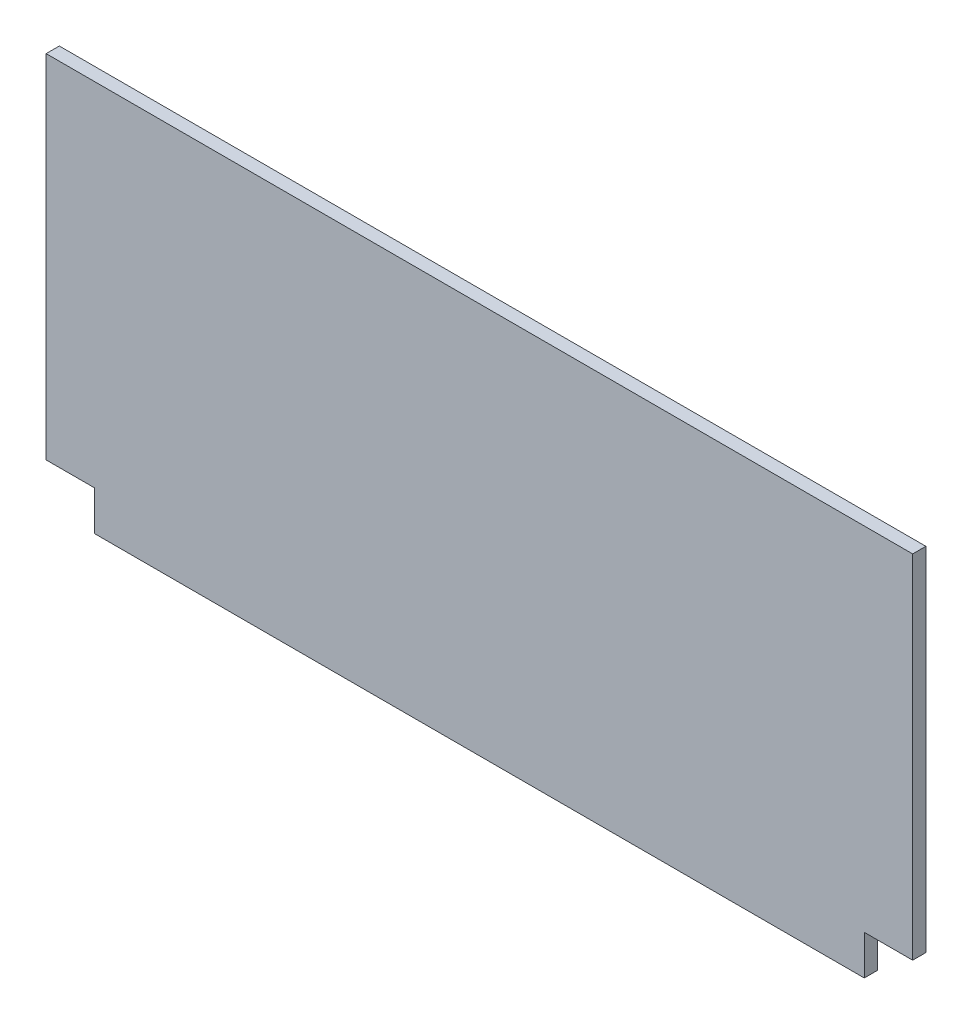
from build123d import *

# Parameters (mm, degrees)
AUFSATZ_LINEAR_AUSTRAGEN1_DEPTH = 3


with BuildPart() as part:
    # Skizze1 → Aufsatz-Linear austragen1 (new body)
    with BuildSketch(Plane.XY):
        Polygon((-87.5, -35.5), (-87.5, -44.5), (87.5, -44.5), (87.5, -35.5), (98.5, -35.5), (98.5, 44.5), (-98.5, 44.5), (-98.5, -35.5), align=None)
    extrude(amount=AUFSATZ_LINEAR_AUSTRAGEN1_DEPTH)


solid = part.part
